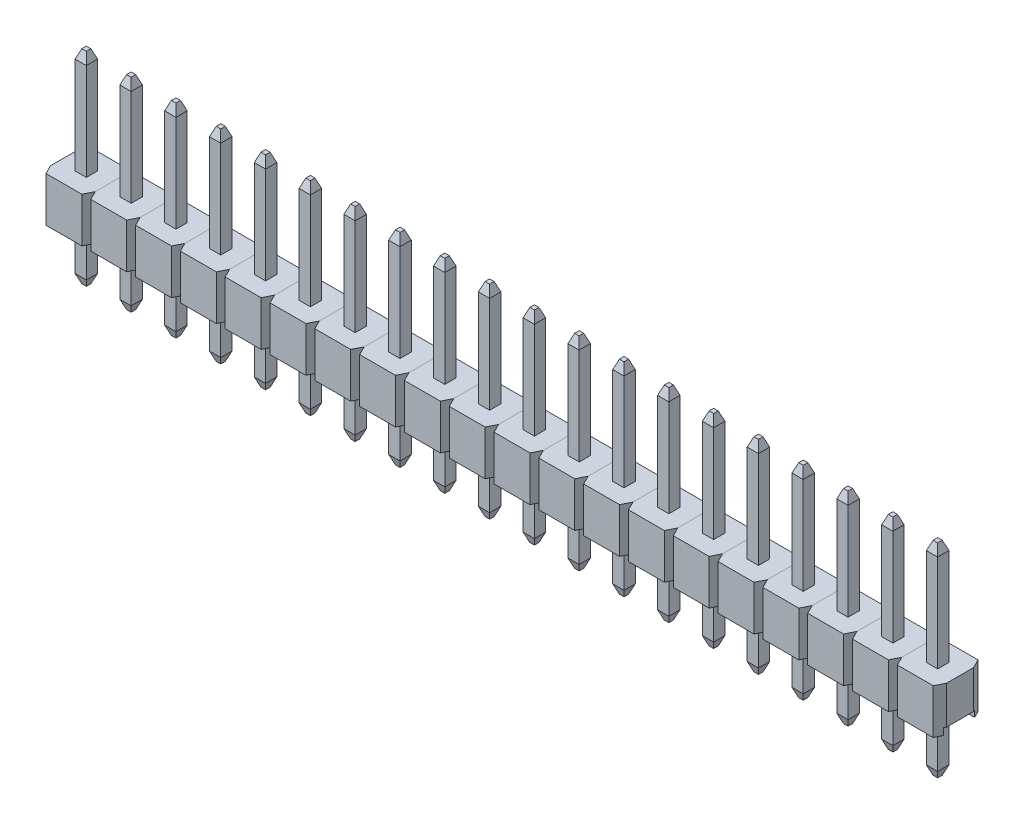
from build123d import *
from OCP.BRepFilletAPI import BRepFilletAPI_MakeChamfer

# Parameters (mm, degrees)
SKETCH1_W             = 2.54
SKETCH1_H             = 2.54
PLASTIC_HOUSING_DEPTH = 2.54
SKETCH3_W             = 1.778
SKETCH3_H             = 0.381
CUT_GROOVE_DEPTH      = 5.399409051
CUT_CORNERS_DEPTH     = 5.399409051
PIN_START             = -5.54
SKETCH2_W             = 0.64
SKETCH2_H             = 0.64
PIN_DEPTH             = 11.54
CHAMF_BOTTOM_SIZE     = 0.1905
CHAMF_BOTTOM_SIZE2    = 0.508
CHAMF_TOP_SIZE        = 0.508
CHAMF_TOP_SIZE2       = 0.1905
PATTERN_SLEEVE_COUNT  = 20
PATTERN_SLEEVE_PITCH  = 2.54
PATTERN_PINS_COUNT    = 20
PATTERN_PINS_PITCH    = 2.54


with BuildPart() as part:
    # Sketch1 → plastic_housing (new body)
    with BuildSketch(Plane(origin=(0, 0, 0), x_dir=(1, 0, 0), z_dir=(0, 1, 0))):
        with Locations((1.27, 1.27)):
            Rectangle(SKETCH1_W, SKETCH1_H)
    extrude(amount=PLASTIC_HOUSING_DEPTH)

    # Sketch3 → cut groove (cut, through all)
    with BuildSketch(Plane.ZY):
        with Locations((-1.27, 0.1905)):
            Rectangle(SKETCH3_W, SKETCH3_H)
    extrude(amount=-CUT_GROOVE_DEPTH, mode=Mode.SUBTRACT)

    # Sketch4 → cut corners (cut, through all)
    with BuildSketch(Plane(origin=(0, 2.54, 0), x_dir=(1, 0, 0), z_dir=(0, 1, 0))):
        Polygon((0.254, 2.54), (0, 2.54), (0, 2.032), align=None)
        Polygon((2.54, 2.54), (2.286, 2.54), (2.54, 2.032), align=None)
        Polygon((0.254, 0), (0, 0.508), (0, 0), align=None)
        Polygon((2.54, 0), (2.286, 0), (2.54, 0.508), align=None)
    extrude(amount=-CUT_CORNERS_DEPTH, mode=Mode.SUBTRACT)


with BuildPart() as body_2:
    # Sketch2 → Pin (new body)
    with BuildSketch(Plane(origin=(0, 2.54, 0), x_dir=(1, 0, 0), z_dir=(0, 1, 0)).offset(PIN_START)):
        with Locations((1.27, 1.27)):
            Rectangle(SKETCH2_W, SKETCH2_H)
    extrude(amount=PIN_DEPTH)

    # chamf_bottom
    chamf_bottom_edges = [body_2.edges().sort_by_distance(p)[0] for p in [
        (1.27, -3, -0.95),
        (1.59, -3, -1.27),
        (1.27, -3, -1.59),
        (0.95, -3, -1.27),
    ]]
    chamf_bottom_side = [body_2.faces().sort_by_distance(p)[0] for p in [
        (1.27, -3, -1.27),
    ]]
    chamfer(chamf_bottom_edges, length=CHAMF_BOTTOM_SIZE, length2=CHAMF_BOTTOM_SIZE2, reference=chamf_bottom_side[0])

    # chamf_top: one chamfer whose edges measure the first distance from different faces: ONE call of the kernel's chamfer builder (chamfer() names one face for all edges)
    chamf_top_edges_1 = [body_2.edges().sort_by_distance(p)[0] for p in [
        (1.27, 8.54, -0.95),
    ]]
    chamf_top_side_1 = [body_2.faces().sort_by_distance(p)[0] for p in [
        (1.27, 3.024, -0.95),
    ]]
    chamf_top_edges_2 = [body_2.edges().sort_by_distance(p)[0] for p in [
        (1.59, 8.54, -1.27),
    ]]
    chamf_top_side_2 = [body_2.faces().sort_by_distance(p)[0] for p in [
        (1.59, 3.024, -1.27),
    ]]
    chamf_top_edges_3 = [body_2.edges().sort_by_distance(p)[0] for p in [
        (1.27, 8.54, -1.59),
    ]]
    chamf_top_side_3 = [body_2.faces().sort_by_distance(p)[0] for p in [
        (1.27, 3.024, -1.59),
    ]]
    chamf_top_edges_4 = [body_2.edges().sort_by_distance(p)[0] for p in [
        (0.95, 8.54, -1.27),
    ]]
    chamf_top_side_4 = [body_2.faces().sort_by_distance(p)[0] for p in [
        (0.95, 3.024, -1.27),
    ]]
    chamf_top = BRepFilletAPI_MakeChamfer(body_2.part.solid().wrapped)
    for e in chamf_top_edges_1:
        chamf_top.Add(CHAMF_TOP_SIZE, CHAMF_TOP_SIZE2, e.wrapped, chamf_top_side_1[0].wrapped)  # the first distance lies on this face
    for e in chamf_top_edges_2:
        chamf_top.Add(CHAMF_TOP_SIZE, CHAMF_TOP_SIZE2, e.wrapped, chamf_top_side_2[0].wrapped)  # the first distance lies on this face
    for e in chamf_top_edges_3:
        chamf_top.Add(CHAMF_TOP_SIZE, CHAMF_TOP_SIZE2, e.wrapped, chamf_top_side_3[0].wrapped)  # the first distance lies on this face
    for e in chamf_top_edges_4:
        chamf_top.Add(CHAMF_TOP_SIZE, CHAMF_TOP_SIZE2, e.wrapped, chamf_top_side_4[0].wrapped)  # the first distance lies on this face
    add(Compound.cast(chamf_top.Shape()), mode=Mode.REPLACE)


with BuildPart() as pattern_sleeve_1:
    # pattern SLEEVE: pattern copy
    add(part.part.moved(Location(Vector(-1, 0, 0) * (1 * PATTERN_SLEEVE_PITCH))))


with BuildPart() as pattern_sleeve_2:
    # pattern SLEEVE: pattern copy
    add(part.part.moved(Location(Vector(-1, 0, 0) * (2 * PATTERN_SLEEVE_PITCH))))


with BuildPart() as pattern_sleeve_3:
    # pattern SLEEVE: pattern copy
    add(part.part.moved(Location(Vector(-1, 0, 0) * (3 * PATTERN_SLEEVE_PITCH))))


with BuildPart() as pattern_sleeve_4:
    # pattern SLEEVE: pattern copy
    add(part.part.moved(Location(Vector(-1, 0, 0) * (4 * PATTERN_SLEEVE_PITCH))))


with BuildPart() as pattern_sleeve_5:
    # pattern SLEEVE: pattern copy
    add(part.part.moved(Location(Vector(-1, 0, 0) * (5 * PATTERN_SLEEVE_PITCH))))


with BuildPart() as pattern_sleeve_6:
    # pattern SLEEVE: pattern copy
    add(part.part.moved(Location(Vector(-1, 0, 0) * (6 * PATTERN_SLEEVE_PITCH))))


with BuildPart() as pattern_sleeve_7:
    # pattern SLEEVE: pattern copy
    add(part.part.moved(Location(Vector(-1, 0, 0) * (7 * PATTERN_SLEEVE_PITCH))))


with BuildPart() as pattern_sleeve_8:
    # pattern SLEEVE: pattern copy
    add(part.part.moved(Location(Vector(-1, 0, 0) * (8 * PATTERN_SLEEVE_PITCH))))


with BuildPart() as pattern_sleeve_9:
    # pattern SLEEVE: pattern copy
    add(part.part.moved(Location(Vector(-1, 0, 0) * (9 * PATTERN_SLEEVE_PITCH))))


with BuildPart() as pattern_sleeve_10:
    # pattern SLEEVE: pattern copy
    add(part.part.moved(Location(Vector(-1, 0, 0) * (10 * PATTERN_SLEEVE_PITCH))))


with BuildPart() as pattern_sleeve_11:
    # pattern SLEEVE: pattern copy
    add(part.part.moved(Location(Vector(-1, 0, 0) * (11 * PATTERN_SLEEVE_PITCH))))


with BuildPart() as pattern_sleeve_12:
    # pattern SLEEVE: pattern copy
    add(part.part.moved(Location(Vector(-1, 0, 0) * (12 * PATTERN_SLEEVE_PITCH))))


with BuildPart() as pattern_sleeve_13:
    # pattern SLEEVE: pattern copy
    add(part.part.moved(Location(Vector(-1, 0, 0) * (13 * PATTERN_SLEEVE_PITCH))))


with BuildPart() as pattern_sleeve_14:
    # pattern SLEEVE: pattern copy
    add(part.part.moved(Location(Vector(-1, 0, 0) * (14 * PATTERN_SLEEVE_PITCH))))


with BuildPart() as pattern_sleeve_15:
    # pattern SLEEVE: pattern copy
    add(part.part.moved(Location(Vector(-1, 0, 0) * (15 * PATTERN_SLEEVE_PITCH))))


with BuildPart() as pattern_sleeve_16:
    # pattern SLEEVE: pattern copy
    add(part.part.moved(Location(Vector(-1, 0, 0) * (16 * PATTERN_SLEEVE_PITCH))))


with BuildPart() as pattern_sleeve_17:
    # pattern SLEEVE: pattern copy
    add(part.part.moved(Location(Vector(-1, 0, 0) * (17 * PATTERN_SLEEVE_PITCH))))


with BuildPart() as pattern_sleeve_18:
    # pattern SLEEVE: pattern copy
    add(part.part.moved(Location(Vector(-1, 0, 0) * (18 * PATTERN_SLEEVE_PITCH))))


with BuildPart() as pattern_sleeve_19:
    # pattern SLEEVE: pattern copy
    add(part.part.moved(Location(Vector(-1, 0, 0) * (19 * PATTERN_SLEEVE_PITCH))))


with BuildPart() as pattern_pins_1:
    # pattern PINS: pattern copy
    add(body_2.part.moved(Location(Vector(-1, 0, 0) * (1 * PATTERN_PINS_PITCH))))


with BuildPart() as pattern_pins_2:
    # pattern PINS: pattern copy
    add(body_2.part.moved(Location(Vector(-1, 0, 0) * (2 * PATTERN_PINS_PITCH))))


with BuildPart() as pattern_pins_3:
    # pattern PINS: pattern copy
    add(body_2.part.moved(Location(Vector(-1, 0, 0) * (3 * PATTERN_PINS_PITCH))))


with BuildPart() as pattern_pins_4:
    # pattern PINS: pattern copy
    add(body_2.part.moved(Location(Vector(-1, 0, 0) * (4 * PATTERN_PINS_PITCH))))


with BuildPart() as pattern_pins_5:
    # pattern PINS: pattern copy
    add(body_2.part.moved(Location(Vector(-1, 0, 0) * (5 * PATTERN_PINS_PITCH))))


with BuildPart() as pattern_pins_6:
    # pattern PINS: pattern copy
    add(body_2.part.moved(Location(Vector(-1, 0, 0) * (6 * PATTERN_PINS_PITCH))))


with BuildPart() as pattern_pins_7:
    # pattern PINS: pattern copy
    add(body_2.part.moved(Location(Vector(-1, 0, 0) * (7 * PATTERN_PINS_PITCH))))


with BuildPart() as pattern_pins_8:
    # pattern PINS: pattern copy
    add(body_2.part.moved(Location(Vector(-1, 0, 0) * (8 * PATTERN_PINS_PITCH))))


with BuildPart() as pattern_pins_9:
    # pattern PINS: pattern copy
    add(body_2.part.moved(Location(Vector(-1, 0, 0) * (9 * PATTERN_PINS_PITCH))))


with BuildPart() as pattern_pins_10:
    # pattern PINS: pattern copy
    add(body_2.part.moved(Location(Vector(-1, 0, 0) * (10 * PATTERN_PINS_PITCH))))


with BuildPart() as pattern_pins_11:
    # pattern PINS: pattern copy
    add(body_2.part.moved(Location(Vector(-1, 0, 0) * (11 * PATTERN_PINS_PITCH))))


with BuildPart() as pattern_pins_12:
    # pattern PINS: pattern copy
    add(body_2.part.moved(Location(Vector(-1, 0, 0) * (12 * PATTERN_PINS_PITCH))))


with BuildPart() as pattern_pins_13:
    # pattern PINS: pattern copy
    add(body_2.part.moved(Location(Vector(-1, 0, 0) * (13 * PATTERN_PINS_PITCH))))


with BuildPart() as pattern_pins_14:
    # pattern PINS: pattern copy
    add(body_2.part.moved(Location(Vector(-1, 0, 0) * (14 * PATTERN_PINS_PITCH))))


with BuildPart() as pattern_pins_15:
    # pattern PINS: pattern copy
    add(body_2.part.moved(Location(Vector(-1, 0, 0) * (15 * PATTERN_PINS_PITCH))))


with BuildPart() as pattern_pins_16:
    # pattern PINS: pattern copy
    add(body_2.part.moved(Location(Vector(-1, 0, 0) * (16 * PATTERN_PINS_PITCH))))


with BuildPart() as pattern_pins_17:
    # pattern PINS: pattern copy
    add(body_2.part.moved(Location(Vector(-1, 0, 0) * (17 * PATTERN_PINS_PITCH))))


with BuildPart() as pattern_pins_18:
    # pattern PINS: pattern copy
    add(body_2.part.moved(Location(Vector(-1, 0, 0) * (18 * PATTERN_PINS_PITCH))))


with BuildPart() as pattern_pins_19:
    # pattern PINS: pattern copy
    add(body_2.part.moved(Location(Vector(-1, 0, 0) * (19 * PATTERN_PINS_PITCH))))


solid = Compound([part.part, body_2.part, pattern_sleeve_1.part, pattern_sleeve_2.part, pattern_sleeve_3.part, pattern_sleeve_4.part, pattern_sleeve_5.part, pattern_sleeve_6.part, pattern_sleeve_7.part, pattern_sleeve_8.part, pattern_sleeve_9.part, pattern_sleeve_10.part, pattern_sleeve_11.part, pattern_sleeve_12.part, pattern_sleeve_13.part, pattern_sleeve_14.part, pattern_sleeve_15.part, pattern_sleeve_16.part, pattern_sleeve_17.part, pattern_sleeve_18.part, pattern_sleeve_19.part, pattern_pins_1.part, pattern_pins_2.part, pattern_pins_3.part, pattern_pins_4.part, pattern_pins_5.part, pattern_pins_6.part, pattern_pins_7.part, pattern_pins_8.part, pattern_pins_9.part, pattern_pins_10.part, pattern_pins_11.part, pattern_pins_12.part, pattern_pins_13.part, pattern_pins_14.part, pattern_pins_15.part, pattern_pins_16.part, pattern_pins_17.part, pattern_pins_18.part, pattern_pins_19.part])
